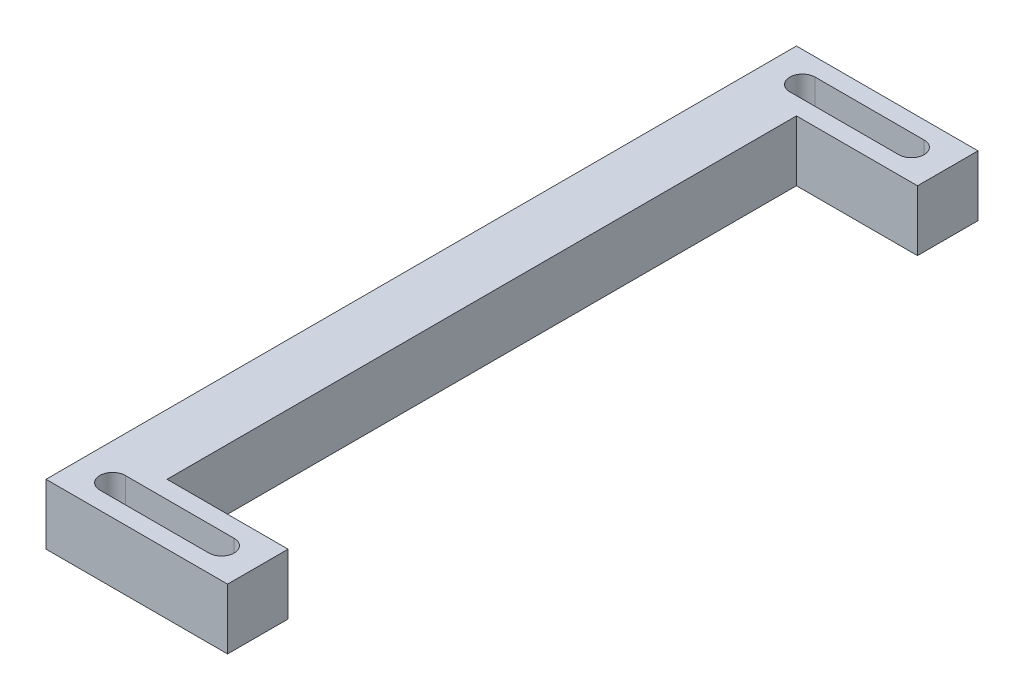
from build123d import *

# Parameters (mm, degrees)
BOSS_EXTRU_3_DEPTH = 10


with BuildPart() as part:
    # Esquisse5 → Boss.-Extru.3 (new body)
    with BuildSketch(Plane(origin=(0, 0, 0), x_dir=(1, 0, 0), z_dir=(0, 1, 0))):
        Polygon((-57, 52), (-57, 62), (-87, 62), (-87, -62), (-57, -62), (-57, -52), (-77, -52), (-77, 52), align=None)
        with BuildLine():
            Line((-81, 59.1), (-63, 59.1))
            ThreePointArc((-63, 59.1), (-60.9, 57), (-63, 54.9))
            Line((-63, 54.9), (-81, 54.9))
            ThreePointArc((-81, 54.9), (-83.1, 57), (-81, 59.1))
        make_face(mode=Mode.SUBTRACT)
        with BuildLine():
            Line((-81, -59.1), (-63, -59.1))
            ThreePointArc((-63, -59.1), (-60.9, -57), (-63, -54.9))
            Line((-63, -54.9), (-81, -54.9))
            ThreePointArc((-81, -54.9), (-83.1, -57), (-81, -59.1))
        make_face(mode=Mode.SUBTRACT)
    extrude(amount=BOSS_EXTRU_3_DEPTH)


solid = part.part
